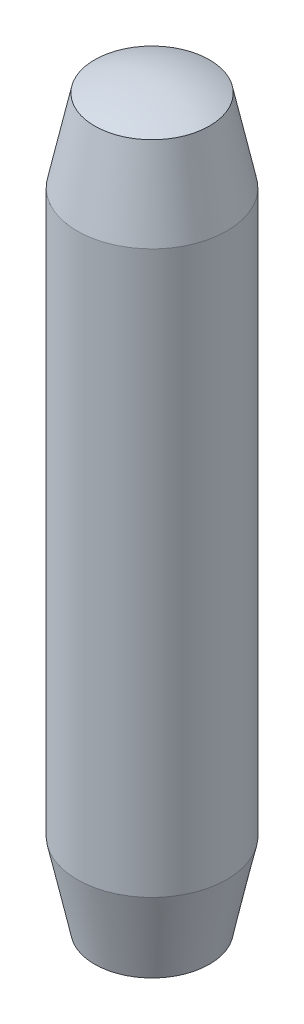
from build123d import *

# Parameters (mm, degrees)
SKETCH1_R           = 0.4
BOSS_EXTRUDE1_DEPTH = 4


with BuildPart() as part:
    # Sketch1 → Boss-Extrude1 (new body)
    with BuildSketch(Plane(origin=(0, 0, 0), x_dir=(1, 0, 0), z_dir=(0, 1, 0))):
        Circle(SKETCH1_R)
    extrude(amount=BOSS_EXTRUDE1_DEPTH)

    # Sketch2 → Cut-Revolve2 (revolve, cut)
    with BuildSketch(Plane.XY):
        with BuildLine():
            Line((0.4, 3.892820323), (0.4, 4.1))
            Line((0.4, 4.1), (0, 4.1))
            Line((0, 4.1), (0, 4))
            ThreePointArc((0, 4), (0.207055236, 3.972740661), (0.4, 3.892820323))
        make_face()
        with BuildLine():
            Line((0.4, -0.1), (0, -0.1))
            Line((0, -0.1), (0, 0))
            ThreePointArc((0, 0), (0.207055236, 0.027259339), (0.4, 0.107179677))
            Line((0.4, 0.107179677), (0.4, -0.1))
        make_face()
    revolve(axis=Axis((0, 0, 0), (0, 1, 0)), mode=Mode.SUBTRACT)

    # Sketch3 → Cut-Revolve3 (revolve, cut)
    with BuildSketch(Plane.XY):
        with BuildLine():
            Line((-0.4, 3.5), (-0.306715799, 3.93886766))
            ThreePointArc((-0.306715799, 3.93886766), (-0.354107179, 3.917361907), (-0.4, 3.892820323))
            Line((-0.4, 3.892820323), (-0.4, 3.5))
        make_face()
        with BuildLine():
            Line((-0.4, 0.107179677), (-0.4, 0.5))
            Line((-0.4, 0.5), (-0.306715799, 0.06113234))
            ThreePointArc((-0.306715799, 0.06113234), (-0.354107179, 0.082638093), (-0.4, 0.107179677))
        make_face()
    revolve(axis=Axis((0, 0, 0), (0, 1, 0)), mode=Mode.SUBTRACT)


solid = part.part
